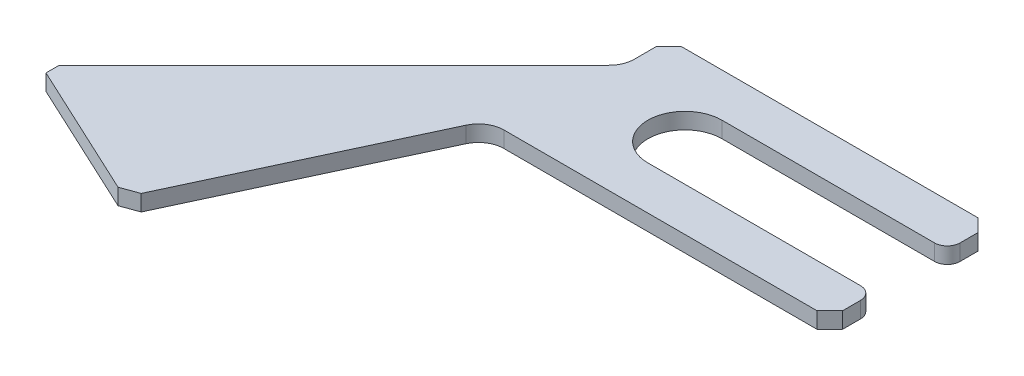
from build123d import *

# Parameters (mm, degrees)
BOSS_EXTRUDE1_DEPTH   = 1
CUT_EXTRUDE1_DEPTH    = 2
FILLET1_R             = 0.79375
CHAMFER1_SIZE         = 0.79375
CHAMFER1_EDGE_2_SIZE  = 0.79375
CHAMFER1_EDGE_3_SIZE  = 0.619288519
CHAMFER1_EDGE_3_SIZE2 = 0.79375
CHAMFER1_EDGE_4_SIZE  = 0.79375
CHAMFER1_EDGE_5_SIZE  = 0.79375


with BuildPart() as part:
    # Sketch1 → Boss-Extrude1 (new body)
    with BuildSketch(Plane(origin=(0, 0, 0), x_dir=(1, 0, 0), z_dir=(0, 1, 0))):
        with BuildLine():
            Line((-11.680023612, -5.916593509), (-18.433746975, -20.4))
            Line((-18.433746975, -20.4), (-28.1, -15.892552189))
            Line((-28.1, -15.892552189), (-10.464967985, 1.742479827))
            ThreePointArc((-10.464967985, 1.742479827), (-10.120841242, 2.257501893), (-10, 2.865011842))
            Line((-10, 2.865011842), (-10, 5))
            Line((-10, 5), (10, 5))
            Line((10, 5), (10, -5))
            Line((10, -5), (-10.24126, -5))
            ThreePointArc((-10.24126, -5), (-11.094223128, -5.24861608), (-11.680023612, -5.916593509))
        make_face()
    extrude(amount=BOSS_EXTRUDE1_DEPTH)

    # Sketch2 → Cut-Extrude1 (cut, through all)
    with BuildSketch(Plane(origin=(0, 1, 0), x_dir=(1, 0, 0), z_dir=(0, 1, 0))):
        with BuildLine():
            Line((-3.99999994, 2.3), (10, 2.3))
            Line((10, 2.3), (10, -2.3))
            Line((10, -2.3), (-3.99999994, -2.3))
            ThreePointArc((-3.99999994, -2.3), (-6.29999994, 0), (-3.99999994, 2.3))
        make_face()
    extrude(amount=-CUT_EXTRUDE1_DEPTH, mode=Mode.SUBTRACT)

    # Fillet1
    fillet1_edges = [part.edges().sort_by_distance(p)[0] for p in [
        (10, 0.5, -2.3),
        (10, 0.5, 2.3),
    ]]
    fillet(fillet1_edges, radius=FILLET1_R)

    # Chamfer1
    chamfer1_edges = [part.edges().sort_by_distance(p)[0] for p in [
        (10, 0.5, 5),
    ]]
    chamfer(chamfer1_edges, length=CHAMFER1_SIZE)

    # Chamfer1 edge 2
    chamfer1_edge_2_edges = [part.edges().sort_by_distance(p)[0] for p in [
        (-18.433746975, 0.5, 20.4),
    ]]
    chamfer(chamfer1_edge_2_edges, length=CHAMFER1_EDGE_2_SIZE)

    # Chamfer1 edge 3
    chamfer1_edge_3_edges = [part.edges().sort_by_distance(p)[0] for p in [
        (-28.1, 0.5, 15.892552189),
    ]]
    chamfer1_edge_3_side = [part.faces().sort_by_distance(p)[0] for p in [
        (-23.266873487, 0.5, 18.146276094),
    ]]
    chamfer(chamfer1_edge_3_edges, length=CHAMFER1_EDGE_3_SIZE, length2=CHAMFER1_EDGE_3_SIZE2, reference=chamfer1_edge_3_side[0])

    # Chamfer1 edge 4
    chamfer1_edge_4_edges = [part.edges().sort_by_distance(p)[0] for p in [
        (-10, 0.5, -5),
    ]]
    chamfer(chamfer1_edge_4_edges, length=CHAMFER1_EDGE_4_SIZE)

    # Chamfer1 edge 5
    chamfer1_edge_5_edges = [part.edges().sort_by_distance(p)[0] for p in [
        (10, 0.5, -5),
    ]]
    chamfer(chamfer1_edge_5_edges, length=CHAMFER1_EDGE_5_SIZE)


solid = part.part
